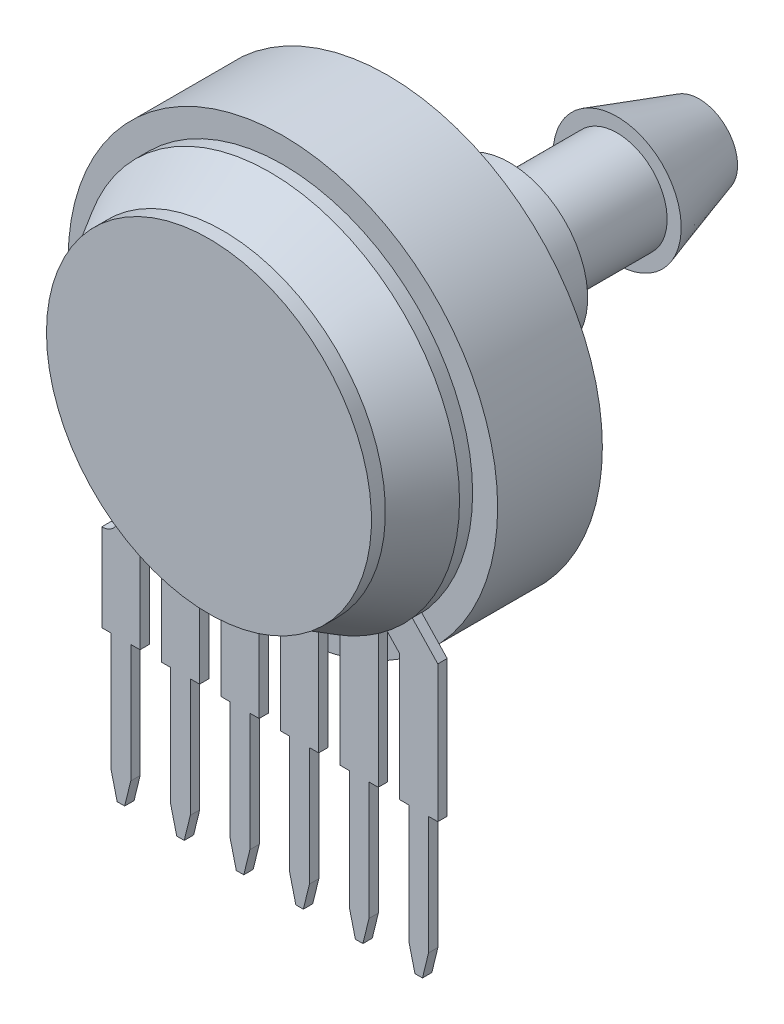
from build123d import *

# Parameters (mm, degrees)
EXTRUDE6_DEPTH        = 0.2
EXTRUDE6_DEPTH_BACK   = 0.2
EXTRUDE6_2_DEPTH      = 0.2
EXTRUDE6_2_DEPTH_BACK = 0.2
EXTRUDE6_3_DEPTH      = 0.2
EXTRUDE6_3_DEPTH_BACK = 0.2
EXTRUDE6_4_DEPTH      = 0.2
EXTRUDE6_4_DEPTH_BACK = 0.2
EXTRUDE6_5_DEPTH      = 0.2
EXTRUDE6_5_DEPTH_BACK = 0.2
EXTRUDE6_6_DEPTH      = 0.2
EXTRUDE6_6_DEPTH_BACK = 0.2


with BuildPart() as part:
    # Sketch7 → Extrude6 (new body, two sides)
    with BuildSketch(Plane.XY) as extrude6_sk:
        with BuildLine():
            Line((-5.93, -12.32), (-5.535, -12.32))
            Line((-5.535, -12.32), (-5.535, -6.923244628))
            Line((-5.535, -6.923244628), (-4.893151867, -6.24528278))
            ThreePointArc((-4.893151867, -6.24528278), (-5.454552369, -5.761453866), (-5.968357327, -5.227351434))
            Line((-5.968357327, -5.227351434), (-7.165, -6.49132345))
            Line((-7.165, -6.49132345), (-7.165, -7.17281133))
            ThreePointArc((-7.165, -7.17281133), (-6.454703172, -7.883108158), (-7.165, -8.593404986))
            Line((-7.165, -8.593404986), (-7.165, -12.32))
            Line((-7.165, -12.32), (-6.77, -12.32))
            Line((-6.77, -12.32), (-6.77, -17.360738904))
            Line((-6.77, -17.360738904), (-6.510329667, -18.42))
            Line((-6.510329667, -18.42), (-6.189670333, -18.42))
            Line((-6.189670333, -18.42), (-5.93, -17.360738904))
            Line((-5.93, -17.360738904), (-5.93, -12.32))
        make_face()
    extrude(amount=EXTRUDE6_DEPTH)
    extrude(extrude6_sk.sketch, amount=-EXTRUDE6_DEPTH_BACK)


with BuildPart() as body_2:
    # Sketch7 → Extrude6 2 (new body, two sides)
    with BuildSketch(Plane.XY) as extrude6_2_sk:
        with BuildLine():
            Line((-4.625, -6.446384041), (-4.625, -12.32))
            Line((-4.625, -12.32), (-4.23, -12.32))
            Line((-4.23, -12.32), (-4.23, -17.360738904))
            Line((-4.23, -17.360738904), (-3.970329667, -18.42))
            Line((-3.970329667, -18.42), (-3.649670333, -18.42))
            Line((-3.649670333, -18.42), (-3.39, -17.360738904))
            Line((-3.39, -17.360738904), (-3.39, -12.32))
            Line((-3.39, -12.32), (-2.995, -12.32))
            Line((-2.995, -12.32), (-2.995, -7.34686785))
            ThreePointArc((-2.995, -7.34686785), (-3.836511146, -6.944614779), (-4.625, -6.446384041))
        make_face()
    extrude(amount=EXTRUDE6_2_DEPTH)
    extrude(extrude6_2_sk.sketch, amount=-EXTRUDE6_2_DEPTH_BACK)


with BuildPart() as body_3:
    # Sketch7 → Extrude6 3 (new body, two sides)
    with BuildSketch(Plane.XY) as extrude6_3_sk:
        with BuildLine():
            Line((-0.455, -12.32), (-0.455, -7.920824907))
            ThreePointArc((-0.455, -7.920824907), (-1.276935244, -7.830448811), (-2.085, -7.65501582))
            Line((-2.085, -7.65501582), (-2.085, -12.32))
            Line((-2.085, -12.32), (-1.69, -12.32))
            Line((-1.69, -12.32), (-1.69, -17.360738904))
            Line((-1.69, -17.360738904), (-1.430329667, -18.42))
            Line((-1.430329667, -18.42), (-1.109670333, -18.42))
            Line((-1.109670333, -18.42), (-0.85, -17.360738904))
            Line((-0.85, -17.360738904), (-0.85, -12.32))
            Line((-0.85, -12.32), (-0.455, -12.32))
        make_face()
    extrude(amount=EXTRUDE6_3_DEPTH)
    extrude(extrude6_3_sk.sketch, amount=-EXTRUDE6_3_DEPTH_BACK)


with BuildPart() as body_4:
    # Sketch7 → Extrude6 4 (new body, two sides)
    with BuildSketch(Plane.XY) as extrude6_4_sk:
        with BuildLine():
            Line((4.625, -12.32), (4.625, -6.446384041))
            ThreePointArc((4.625, -6.446384041), (3.836511146, -6.944614779), (2.995, -7.34686785))
            Line((2.995, -7.34686785), (2.995, -12.32))
            Line((2.995, -12.32), (3.39, -12.32))
            Line((3.39, -12.32), (3.39, -17.360738904))
            Line((3.39, -17.360738904), (3.649670333, -18.42))
            Line((3.649670333, -18.42), (3.970329667, -18.42))
            Line((3.970329667, -18.42), (4.23, -17.360738904))
            Line((4.23, -17.360738904), (4.23, -12.32))
            Line((4.23, -12.32), (4.625, -12.32))
        make_face()
    extrude(amount=EXTRUDE6_4_DEPTH)
    extrude(extrude6_4_sk.sketch, amount=-EXTRUDE6_4_DEPTH_BACK)


with BuildPart() as body_5:
    # Sketch7 → Extrude6 5 (new body, two sides)
    with BuildSketch(Plane.XY) as extrude6_5_sk:
        with BuildLine():
            Line((0.455, -7.920824907), (0.455, -12.32))
            Line((0.455, -12.32), (0.85, -12.32))
            Line((0.85, -12.32), (0.85, -17.360738904))
            Line((0.85, -17.360738904), (1.109670333, -18.42))
            Line((1.109670333, -18.42), (1.430329667, -18.42))
            Line((1.430329667, -18.42), (1.69, -17.360738904))
            Line((1.69, -17.360738904), (1.69, -12.32))
            Line((1.69, -12.32), (2.085, -12.32))
            Line((2.085, -12.32), (2.085, -7.65501582))
            ThreePointArc((2.085, -7.65501582), (1.276935244, -7.830448811), (0.455, -7.920824907))
        make_face()
    extrude(amount=EXTRUDE6_5_DEPTH)
    extrude(extrude6_5_sk.sketch, amount=-EXTRUDE6_5_DEPTH_BACK)


with BuildPart() as body_6:
    # Sketch7 → Extrude6 6 (new body, two sides)
    with BuildSketch(Plane.XY) as extrude6_6_sk:
        with BuildLine():
            Line((5.535, -12.32), (5.93, -12.32))
            Line((5.93, -12.32), (5.93, -17.360738904))
            Line((5.93, -17.360738904), (6.189670333, -18.42))
            Line((6.189670333, -18.42), (6.510329667, -18.42))
            Line((6.510329667, -18.42), (6.77, -17.360738904))
            Line((6.77, -17.360738904), (6.77, -12.32))
            Line((6.77, -12.32), (7.165, -12.32))
            Line((7.165, -12.32), (7.165, -6.49132345))
            Line((7.165, -6.49132345), (5.968357327, -5.227351434))
            ThreePointArc((5.968357327, -5.227351434), (5.454552369, -5.761453866), (4.893151867, -6.24528278))
            Line((4.893151867, -6.24528278), (5.535, -6.923244628))
            Line((5.535, -6.923244628), (5.535, -12.32))
        make_face()
    extrude(amount=EXTRUDE6_6_DEPTH)
    extrude(extrude6_6_sk.sketch, amount=-EXTRUDE6_6_DEPTH_BACK)


with BuildPart() as body_7:
    # Sketch8 → Revolve1 (revolve)
    with BuildSketch(Plane(origin=(0, 0, 0), x_dir=(0, 0, -1), z_dir=(1, 0, 0))):
        Polygon((0.358195537, -9.159281465), (0.358195537, -8.091601843), (-0.2, -8.091601843), (-2.200853855, -6.93), (-2.795, -6.93), (-2.795, 0), (18.110064994, 0), (18.110064994, -1.640232074), (14.612633893, -2.733179292), (14.612633893, -2.132058322), (10.022255574, -2.132058322), (10.022255574, -3.334300263), (5.267935171, -3.334300263), (5.267935171, -6.503847198), (4.823772505, -6.503847198), (4.823772505, -9.159281465), align=None)
    revolve(axis=Axis((0, 0, 0), (0, 0, 1)))

    # Sketch9 → Ø1.0 (1) Diameter Hole1 (revolve, cut)
    with BuildSketch(Plane(origin=(0, 0, -18.110064994), x_dir=(0, 1, 0), z_dir=(1, 0, 0))):
        Polygon((0, 0), (0, 14.27043031), (0.5, 13.97), (0.5, 0), align=None)
    revolve(axis=Axis((0, 0, -24.460064994), (0, 0, 1)), mode=Mode.SUBTRACT)


solid = Compound([part.part, body_2.part, body_3.part, body_4.part, body_5.part, body_6.part, body_7.part])
